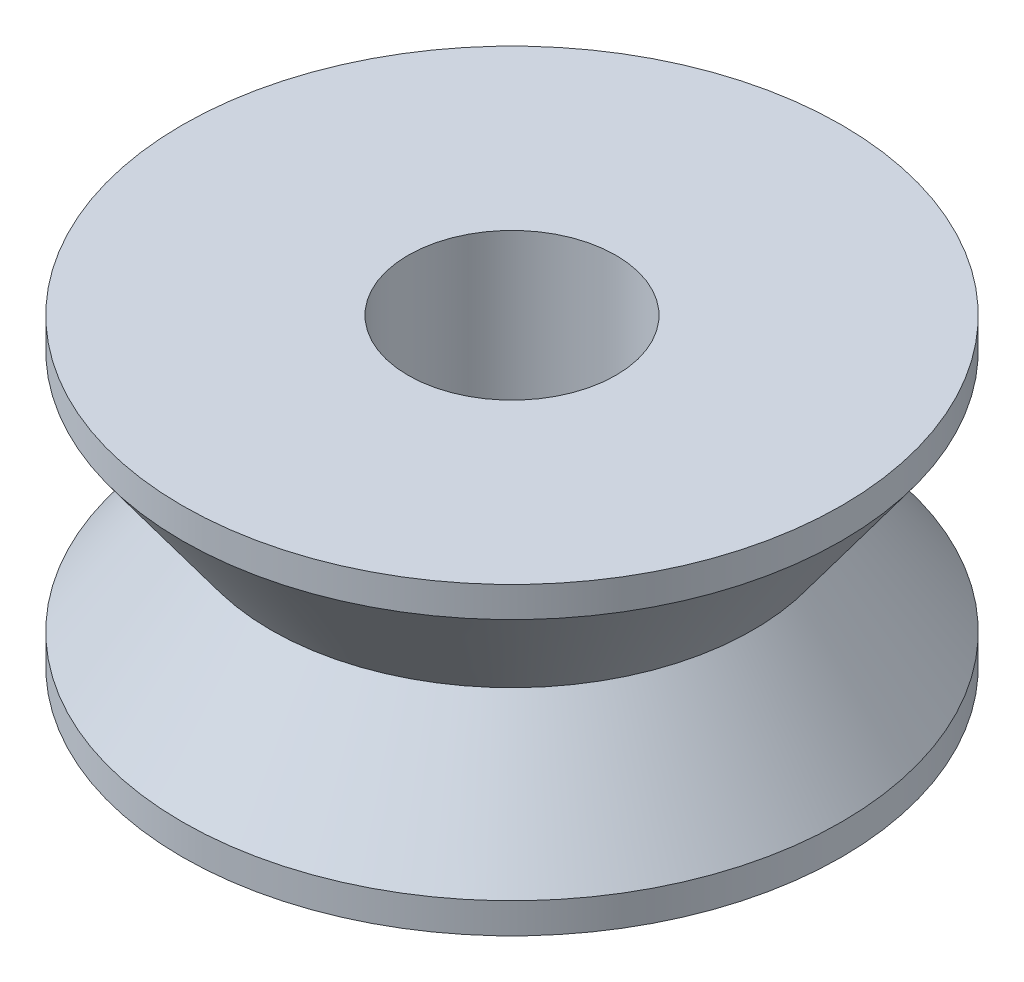
from build123d import *

# Parameters (mm, degrees)
CUT_EXTRUDE1_REACH = 8
SKETCH2_R          = 2.05


with BuildPart() as part:
    # Sketch1 → Revolve1 (revolve)
    with BuildSketch(Plane.XY):
        Polygon((0, 6), (6.5, 6), (6.5, 5.4), (4.75, 3), (6.5, 0.6), (6.5, 0), (0, 0), align=None)
    revolve(axis=Axis((0, 0, 0), (0, 1, 0)))

    # Sketch2 → Cut-Extrude1 (cut, up to next)
    with BuildSketch(Plane(origin=(0, 6, 0), x_dir=(1, 0, 0), z_dir=(0, 1, 0)), mode=Mode.PRIVATE) as cut_extrude1_sk1:
        Circle(SKETCH2_R)
    cut_extrude1_tool1 = extrude(cut_extrude1_sk1.sketch, amount=-CUT_EXTRUDE1_REACH, mode=Mode.PRIVATE) & part.part
    add(cut_extrude1_tool1.solids().sort_by_distance((0, 6, 0))[0], mode=Mode.SUBTRACT)


solid = part.part
